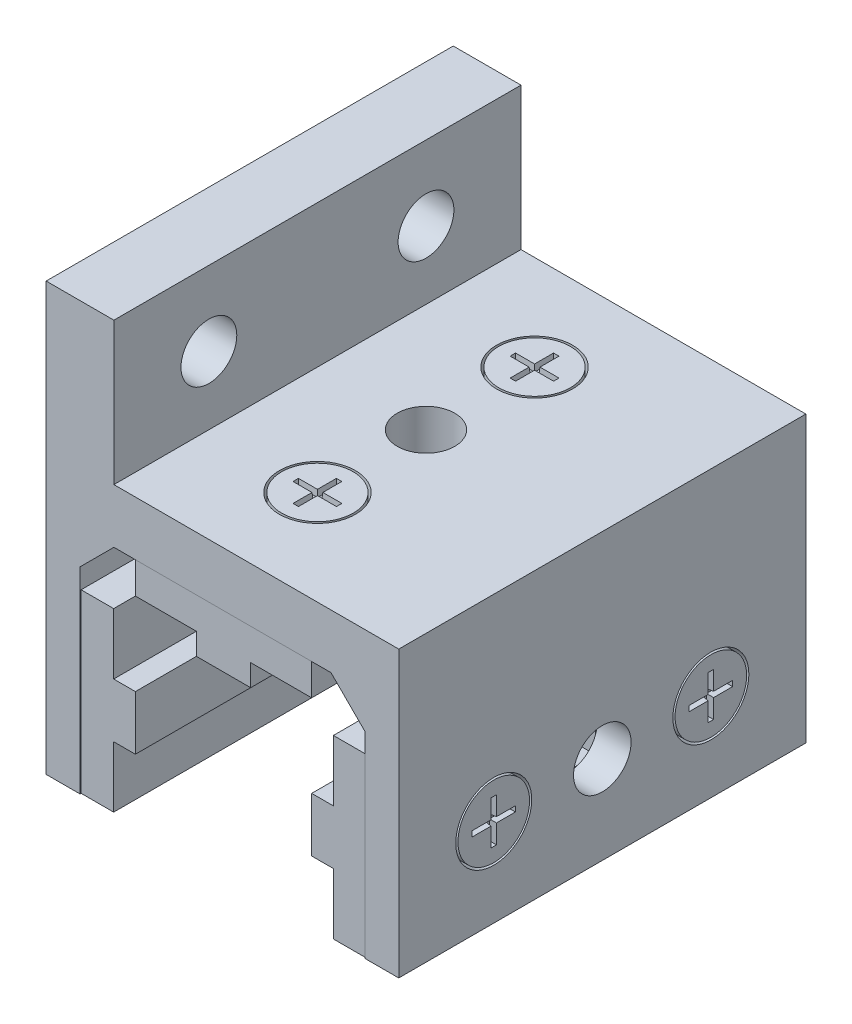
from build123d import *

# Parameters (mm, degrees)
BOSS_EXTRUDE1_DEPTH       = 23.8125
BOSS_EXTRUDE2_DEPTH       = 23.6855
BOSS_EXTRUDE2_2_DEPTH     = 23.6855
SKETCH11_W                = 6.35
SKETCH11_H                = 6.35
CUT_EXTRUDE5_DEPTH        = 11.3124
SKETCH12_W                = 6.35
SKETCH12_H                = 6.35
CUT_EXTRUDE6_DEPTH        = 13.7
SKETCH3_R                 = 4.445
SKETCH3_R_2               = 4.191
CUT_EXTRUDE1_DEPTH        = 3.175
CUT_EXTRUDE2_DEPTH        = 0.762
CUT_EXTRUDE2_TAPER        = 5
SKETCH13_R                = 4.445
SKETCH13_R_2              = 4.191
CUT_EXTRUDE_THIN1_DEPTH   = 1.9812
CUT_EXTRUDE7_DEPTH        = 0.762
CUT_EXTRUDE7_TAPER        = 5
MIRROR3_COPY_1_SKETCH_R   = 4.445
MIRROR3_COPY_1_SKETCH_R_2 = 4.191
MIRROR3_COPY_1_DEPTH      = 1.9812
MIRROR3_COPY_2_DEPTH      = 0.762
MIRROR3_COPY_2_TAPER      = 5
SKETCH9_R                 = 3.3655
CUT_EXTRUDE4_DEPTH        = 34.3248
SKETCH15_R                = 3.3655
CUT_EXTRUDE8_DEPTH        = 21.6248001
CUT_EXTRUDE8_DEPTH_BACK   = 21.6248001
SIDE_START                = -23.8125
SKETCH6_W                 = 7.9248
SKETCH6_H                 = 23.0124
SIDE_FLANGE_DEPTH         = 47.625
SKETCH7_R                 = 3.2639
SIDE_FLANGE_HOLE_DEPTH    = 21.6248001
SKETCH16_W                = 1.9812
SKETCH16_H                = 7.9248
TOP_FLANGE_DEPTH          = 23.8125
TOP_FLANGE_DEPTH_BACK     = 23.8125


with BuildPart() as part:
    # Sketch1 → Boss-Extrude1 (new body, symmetric)
    with BuildSketch(Plane.XY):
        Polygon((-16.6624, 0), (-16.6624, 23.0124), (-12.7, 26.9748), (12.7, 26.9748), (16.6624, 23.0124), (16.6624, 0), (20.6248, 0), (20.6248, 33.3248), (-20.6248, 33.3248), (-20.6248, 0), align=None)
    extrude(amount=BOSS_EXTRUDE1_DEPTH, both=True)

    # Sketch3 → Cut-Extrude1 (cut)
    with BuildSketch(Plane(origin=(0, 33.3248, 0), x_dir=(1, 0, 0), z_dir=(0, 1, 0))):
        with Locations((0, -12.7)):
            Circle(SKETCH3_R)
        with Locations((0, -12.7)):
            Circle(SKETCH3_R_2, mode=Mode.SUBTRACT)
    cut_extrude1 = extrude(amount=-CUT_EXTRUDE1_DEPTH, mode=Mode.SUBTRACT)

    # Sketch5 → Cut-Extrude2 (cut)
    with BuildSketch(Plane(origin=(0, 33.3248, 0), x_dir=(1, 0, 0), z_dir=(0, 1, 0))):
        Polygon((0.3175, -12.3825), (0.3175, -10.16), (-0.3175, -10.16), (-0.3175, -12.3825), (-2.54, -12.3825), (-2.54, -13.0175), (-0.3175, -13.0175), (-0.3175, -15.24), (0.3175, -15.24), (0.3175, -13.0175), (2.54, -13.0175), (2.54, -12.3825), align=None)
    cut_extrude2 = extrude(amount=-CUT_EXTRUDE2_DEPTH, taper=CUT_EXTRUDE2_TAPER, mode=Mode.SUBTRACT)

    # Sketch13 → Cut-Extrude-Thin1 (cut)
    with BuildSketch(Plane(origin=(20.6248, 0, 0), x_dir=(0, 0, -1), z_dir=(1, 0, 0))):
        with Locations((-12.7, 10.3124)):
            Circle(SKETCH13_R)
        with Locations((-12.7, 10.3124)):
            Circle(SKETCH13_R_2, mode=Mode.SUBTRACT)
    cut_extrude_thin1 = extrude(amount=-CUT_EXTRUDE_THIN1_DEPTH, mode=Mode.SUBTRACT)

    # Sketch14 → Cut-Extrude7 (cut)
    with BuildSketch(Plane(origin=(20.6248, 0, 0), x_dir=(0, 0, -1), z_dir=(1, 0, 0))):
        Polygon((-13.0175, 9.9949), (-13.0175, 7.7724), (-12.3825, 7.7724), (-12.3825, 9.9949), (-10.16, 9.9949), (-10.16, 10.6299), (-12.3825, 10.6299), (-12.3825, 12.8524), (-13.0175, 12.8524), (-13.0175, 10.6299), (-15.24, 10.6299), (-15.24, 9.9949), align=None)
    cut_extrude7 = extrude(amount=-CUT_EXTRUDE7_DEPTH, taper=CUT_EXTRUDE7_TAPER, mode=Mode.SUBTRACT)

    # Mirror4: Cut-Extrude-Thin1, Cut-Extrude7 across plane
    add(cut_extrude_thin1.mirror(Plane(origin=(0, 0, 0), x_dir=(0, 0, 1), z_dir=(1, 0, 0))), mode=Mode.SUBTRACT)
    add(cut_extrude7.mirror(Plane(origin=(0, 0, 0), x_dir=(0, 0, 1), z_dir=(1, 0, 0))), mode=Mode.SUBTRACT)

    # Mirror3: Cut-Extrude-Thin1, Cut-Extrude7, Cut-Extrude1, Cut-Extrude2 across plane
    add(cut_extrude_thin1.mirror(Plane.XY), mode=Mode.SUBTRACT)
    add(cut_extrude7.mirror(Plane.XY), mode=Mode.SUBTRACT)
    add(cut_extrude1.mirror(Plane.XY), mode=Mode.SUBTRACT)
    add(cut_extrude2.mirror(Plane.XY), mode=Mode.SUBTRACT)

    # Mirror3 copy 1 sketch → Mirror3 copy 1 (cut)
    with BuildSketch(Plane.ZY.offset(20.6248)):
        with Locations((-12.7, 10.3124)):
            Circle(MIRROR3_COPY_1_SKETCH_R)
        with Locations((-12.7, 10.3124)):
            Circle(MIRROR3_COPY_1_SKETCH_R_2, mode=Mode.SUBTRACT)
    extrude(amount=-MIRROR3_COPY_1_DEPTH, mode=Mode.SUBTRACT)

    # Mirror3 copy 2 sketch → Mirror3 copy 2 (cut)
    with BuildSketch(Plane.ZY.offset(20.6248)):
        Polygon((-13.0175, 9.9949), (-13.0175, 7.7724), (-12.3825, 7.7724), (-12.3825, 9.9949), (-10.16, 9.9949), (-10.16, 10.6299), (-12.3825, 10.6299), (-12.3825, 12.8524), (-13.0175, 12.8524), (-13.0175, 10.6299), (-15.24, 10.6299), (-15.24, 9.9949), align=None)
    extrude(amount=-MIRROR3_COPY_2_DEPTH, taper=MIRROR3_COPY_2_TAPER, mode=Mode.SUBTRACT)

    # Sketch9 → Cut-Extrude4 (cut, through all)
    with BuildSketch(Plane(origin=(0, 33.3248, 0), x_dir=(1, 0, 0), z_dir=(0, 1, 0))):
        Circle(SKETCH9_R)
    extrude(amount=-CUT_EXTRUDE4_DEPTH, mode=Mode.SUBTRACT)

    # Sketch15 → Cut-Extrude8 (cut, two sides)
    with BuildSketch(Plane(origin=(0, 0, 0), x_dir=(0, 0, -1), z_dir=(1, 0, 0))) as cut_extrude8_sk:
        with Locations((0, 10.3124)):
            Circle(SKETCH15_R)
    extrude(amount=CUT_EXTRUDE8_DEPTH, mode=Mode.SUBTRACT)
    extrude(cut_extrude8_sk.sketch, amount=-CUT_EXTRUDE8_DEPTH_BACK, mode=Mode.SUBTRACT)

    # Sketch6 → Side Flange (add)
    with BuildSketch(Plane.XY.offset(SIDE_START)):
        with Locations((-16.6624, 38.481)):
            Rectangle(SKETCH6_W, SKETCH6_H)
    extrude(amount=SIDE_FLANGE_DEPTH)

    # Sketch7 → Side Flange Hole (cut, through all)
    with BuildSketch(Plane(origin=(0, 0, 0), x_dir=(0, 0, -1), z_dir=(1, 0, 0))):
        with Locations((-12.7, 41.275)):
            Circle(SKETCH7_R)
        with Locations((12.7, 41.275)):
            Circle(SKETCH7_R)
    extrude(amount=-SIDE_FLANGE_HOLE_DEPTH, mode=Mode.SUBTRACT)

    # Sketch16 → Top Flange (add, two sides)
    with BuildSketch(Plane.XY) as top_flange_sk:
        with Locations((-19.6342, 29.3624)):
            Rectangle(SKETCH16_W, SKETCH16_H)
        with Locations((19.6342, 29.3624)):
            Rectangle(SKETCH16_W, SKETCH16_H)
    extrude(amount=TOP_FLANGE_DEPTH)
    extrude(top_flange_sk.sketch, amount=-TOP_FLANGE_DEPTH_BACK)


with BuildPart() as body_2:
    # Sketch2 → Boss-Extrude2 (new body, symmetric)
    with BuildSketch(Plane.XY):
        Polygon((-12.8524, 13.4874), (-12.8524, 20.6248), (-16.6624, 20.6248), (-16.6624, 0), (-12.8524, 0), (-12.8524, 7.1374), (-10.3124, 7.1374), (-10.3124, 13.4874), align=None)
    extrude(amount=BOSS_EXTRUDE2_DEPTH, both=True)

    # Sketch11 → Cut-Extrude5 (cut, through all)
    with BuildSketch(Plane(origin=(-10.3124, 0, 0), x_dir=(0, 0, -1), z_dir=(1, 0, 0))):
        with Locations((0, 10.3124)):
            Rectangle(SKETCH11_W, SKETCH11_H)
    extrude(amount=-CUT_EXTRUDE5_DEPTH, mode=Mode.SUBTRACT)


with BuildPart() as body_3:
    # Sketch2 → Boss-Extrude2 2 (new body, symmetric)
    with BuildSketch(Plane.XY):
        Polygon((-10.3124, 26.9748), (10.3124, 26.9748), (10.3124, 23.1648), (3.175, 23.1648), (3.175, 20.6248), (-3.175, 20.6248), (-3.175, 23.1648), (-10.3124, 23.1648), align=None)
    extrude(amount=BOSS_EXTRUDE2_2_DEPTH, both=True)

    # Sketch12 → Cut-Extrude6 (cut, through all)
    with BuildSketch(Plane.XZ.offset(-20.6248)):
        Rectangle(SKETCH12_W, SKETCH12_H)
    extrude(amount=-CUT_EXTRUDE6_DEPTH, mode=Mode.SUBTRACT)


with BuildPart() as body_4:
    # Mirror1: mirrored copy
    add(body_2.part.mirror(Plane(origin=(0, 0, 0), x_dir=(0, 0, 1), z_dir=(1, 0, 0))))


solid = Compound([part.part, body_2.part, body_3.part, body_4.part])
